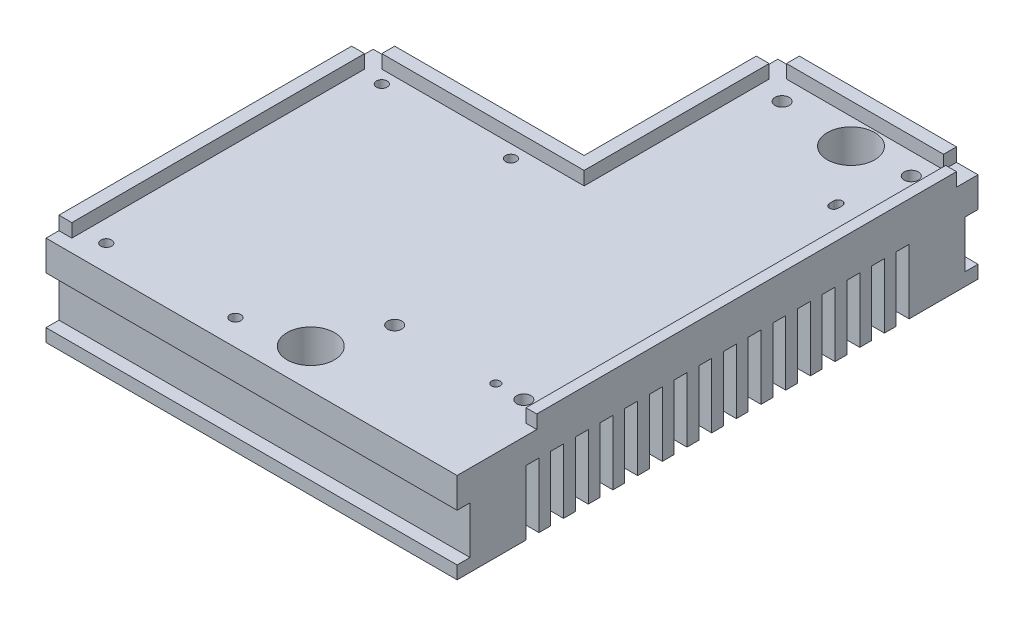
from build123d import *

# Parameters (mm, degrees)
SKETCH_1_W                = 95.5
SKETCH_1_H                = 121
EXTRUDE_1_DEPTH           = 24.125
CUT_EXTRUDE_START         = -3.125
SKETCH_2_W                = 40
SKETCH_2_H                = 70
SKETCH_2_H_2              = 99.5
CUT_EXTRUDE_1_DEPTH       = 3.125
CUT_EXTRUDE_2_DEPTH       = 3.125
HOLE_WIZARD_M3_1_D        = 2.5
HOLE_WIZARD_M3_1_DEPTH    = 5
HOLE_WIZARD_M3_1_TIP      = 0.751075774
HOLE_WIZARD_M4_1_D        = 3.3
HOLE_WIZARD_M4_1_DEPTH    = 5
HOLE_WIZARD_M4_1_TIP      = 0.991420021
MM_2_D                    = 2
MM_2_DEPTH                = 5
MM_2_TIP                  = 0.600860619
CUT_EXTRUDE_12_DEPTH      = 5
SKETCH_27_W               = 49
SKETCH_27_H               = 45
CUT_EXTRUDE_15_DEPTH      = 25.125
CUT_EXTRUDE_16_DEPTH      = 16
CUT_EXTRUDE_17_DEPTH      = 16
FILLET_2_R                = 5
SKETCH_42_W               = 5
SKETCH_42_H               = 5
CUT_EXTRUDE_24_DEPTH      = 3.125
HOLE_WIZARD_2_D           = 6.6
HOLE_WIZARD_2_CBORE_D     = 11
HOLE_WIZARD_2_CBORE_DEPTH = 8
SKETCH_49_W               = 3
SKETCH_49_H               = 11
CUT_EXTRUDE_28_DEPTH      = 96.5
SKETCH_50_W               = 3
SKETCH_50_H               = 3
CUT_EXTRUDE_29_DEPTH      = 4
CUT_EXTRUDE_29_DEPTH_BACK = 13
SKETCH_52_W               = 3
SKETCH_52_H               = 15
CUT_EXTRUDE_30_DEPTH      = 96.5
PATTERN_LINEAR_4_COUNT    = 16
PATTERN_LINEAR_4_PITCH    = 5.733333333
MM_3_D                    = 4
MM_3_DEPTH                = 5
MM_3_TIP                  = 1.201721238


with BuildPart() as part:
    # 草图1 → 凸台-拉伸1 (new body)
    with BuildSketch(Plane(origin=(0, 0, 0), x_dir=(1, 0, 0), z_dir=(0, 1, 0))):
        with Locations((-170.498130707, -443.224508868)):
            Rectangle(SKETCH_1_W, SKETCH_1_H)
    extrude(amount=EXTRUDE_1_DEPTH)

    # 草图2 → 切除-拉伸1 (cut)
    with BuildSketch(Plane(origin=(0, 24.125, 0), x_dir=(1, 0, 0), z_dir=(0, 1, 0)).offset(CUT_EXTRUDE_START)):
        with Locations((-195.248130707, -465.724508868)):
            Rectangle(SKETCH_2_W, SKETCH_2_H)
        with Locations((-145.248130707, -435.474508868)):
            Rectangle(SKETCH_2_W, SKETCH_2_H_2)
    extrude(amount=CUT_EXTRUDE_1_DEPTH, mode=Mode.SUBTRACT)

    # 草图4 → 切除-拉伸2 (cut)
    with BuildSketch(Plane(origin=(0, 24.125, 0), x_dir=(1, 0, 0), z_dir=(0, 1, 0))):
        Polygon((-165.248130707, -385.724508868), (-166.248130707, -385.724508868), (-166.248130707, -430.724508868), (-175.248130707, -430.724508868), (-175.248130707, -500.724508868), (-215.248130707, -500.724508868), (-218.248130707, -500.724508868), (-218.248130707, -503.724508868), (-122.748130707, -503.724508868), (-122.748130707, -485.224508868), (-125.248130707, -485.224508868), (-165.248130707, -485.224508868), align=None)
    extrude(amount=-CUT_EXTRUDE_2_DEPTH, mode=Mode.SUBTRACT)

    # M3 螺纹孔1
    with Locations(Plane(origin=(-210.248130707, 21, 433.724508868), x_dir=(0, 0, 1), z_dir=(0, 1, 0))):
        with Locations((0, 0), (0, 30), (64, 30), (64, 0)):
            Hole(HOLE_WIZARD_M3_1_D / 2, depth=HOLE_WIZARD_M3_1_DEPTH)
            with Locations((0, 0, -(HOLE_WIZARD_M3_1_DEPTH + HOLE_WIZARD_M3_1_TIP / 2))):  # 118° drill point
                Cone(0, HOLE_WIZARD_M3_1_D / 2, HOLE_WIZARD_M3_1_TIP, mode=Mode.SUBTRACT)

    # M4 螺纹孔1
    with Locations(Plane(origin=(-160.248130707, 21, 390.724508868), x_dir=(0, 0, 1), z_dir=(0, 1, 0))):
        with Locations((0, 0), (0, 30), (90, 0), (90, 30)):
            Hole(HOLE_WIZARD_M4_1_D / 2, depth=HOLE_WIZARD_M4_1_DEPTH)
            with Locations((0, 0, -(HOLE_WIZARD_M4_1_DEPTH + HOLE_WIZARD_M4_1_TIP / 2))):  # 118° drill point
                Cone(0, HOLE_WIZARD_M4_1_D / 2, HOLE_WIZARD_M4_1_TIP, mode=Mode.SUBTRACT)

    # 大小mm 暗销孔2
    with Locations(Plane(origin=(-136.748130707, 21, 480.724508868), x_dir=(0, 0, 1), z_dir=(0, 1, 0))):
        with Locations((0, 0)):
            Hole(MM_2_D / 2, depth=MM_2_DEPTH)
            with Locations((0, 0, -(MM_2_DEPTH + MM_2_TIP / 2))):  # 118° drill point
                Cone(0, MM_2_D / 2, MM_2_TIP, mode=Mode.SUBTRACT)

    # 草图24 → 切除-拉伸12 (cut)
    with BuildSketch(Plane(origin=(0, 21, 0), x_dir=(1, 0, 0), z_dir=(0, 1, 0))):
        with BuildLine():
            Line((-134.248130707, -405.724508868), (-134.248130707, -404.724508868))
            ThreePointArc((-134.248130707, -404.724508868), (-133.248130707, -403.724508868), (-132.248130707, -404.724508868))
            Line((-132.248130707, -404.724508868), (-132.248130707, -405.724508868))
            ThreePointArc((-132.248130707, -405.724508868), (-133.248130707, -406.724508868), (-134.248130707, -405.724508868))
        make_face()
    extrude(amount=-CUT_EXTRUDE_12_DEPTH, mode=Mode.SUBTRACT)

    # 草图27 → 切除-拉伸15 (cut, through all)
    with BuildSketch(Plane(origin=(0, 24.125, 0), x_dir=(1, 0, 0), z_dir=(0, 1, 0))):
        with Locations((-193.748130707, -405.224508868)):
            Rectangle(SKETCH_27_W, SKETCH_27_H)
    extrude(amount=-CUT_EXTRUDE_15_DEPTH, mode=Mode.SUBTRACT)

    # 草图28 → 切除-拉伸16 (cut)
    with BuildSketch(Plane(origin=(0, 0, 0), x_dir=(1, 0, 0), z_dir=(0, 1, 0))):
        Polygon((-151.605995083, -389.724508869), (-171.714464048, -409.832977834), (-185.669197391, -395.878244492), (-165.560728425, -375.769775526), align=None)
    extrude(amount=CUT_EXTRUDE_16_DEPTH, mode=Mode.SUBTRACT)

    # 草图29 → 切除-拉伸17 (cut)
    with BuildSketch(Plane.XZ):
        Polygon((-151.605995083, 389.724508869), (-158.605995083, 382.724508868), (-155.777567958, 382.724508868), (-148.777567958, 389.724508869), (-167.833917144, 408.780858055), (-169.248130707, 410.195071617), (-169.248130707, 407.366644492), align=None)
    extrude(amount=-CUT_EXTRUDE_17_DEPTH, mode=Mode.SUBTRACT)

    # 圆角2
    fillet_2_edges = [part.edges().sort_by_distance(p)[0] for p in [
        (-148.777567958, 8, 389.724508869),
    ]]
    fillet(fillet_2_edges, radius=FILLET_2_R)

    # 草图42 → 切除-拉伸24 (cut)
    with BuildSketch(Plane(origin=(0, 24.125, 0), x_dir=(1, 0, 0), z_dir=(0, 1, 0))):
        with Locations((-166.748130707, -385.224508868)):
            Rectangle(SKETCH_42_W, SKETCH_42_H)
        with Locations((-125.248130707, -385.224508868)):
            Rectangle(SKETCH_42_W, SKETCH_42_H)
        with Locations((-215.748130707, -430.224508868)):
            Rectangle(SKETCH_42_W, SKETCH_42_H)
    extrude(amount=-CUT_EXTRUDE_24_DEPTH, mode=Mode.SUBTRACT)

    # 打孔尺寸(%根据)内六角圆柱头螺钉的类型2 (through all)
    with Locations(Plane(origin=(-165.748130707, 21, 494.724508868), x_dir=(0, 0, 1), z_dir=(0, 1, 0))):
        with Locations((0, 0), (-103, 22.5)):
            CounterBoreHole(HOLE_WIZARD_2_D / 2, HOLE_WIZARD_2_CBORE_D / 2, HOLE_WIZARD_2_CBORE_DEPTH)

    # 草图49 → 切除-拉伸28 (cut, through all)
    with BuildSketch(Plane(origin=(-122.748130707, 0, 0), x_dir=(0, 0, -1), z_dir=(1, 0, 0))):
        with Locations((-502.224508868, 8.5)):
            Rectangle(SKETCH_49_W, SKETCH_49_H)
        with Locations((-384.224508868, 8.5)):
            Rectangle(SKETCH_49_W, SKETCH_49_H)
    extrude(amount=-CUT_EXTRUDE_28_DEPTH, mode=Mode.SUBTRACT)

    # 草图50 → 切除-拉伸29 (cut, two sides)
    with BuildSketch(Plane.XZ.offset(-3)) as cut_extrude_29_sk:
        with Locations((-154.277567958, 384.224508868)):
            Rectangle(SKETCH_50_W, SKETCH_50_H)
    extrude(amount=CUT_EXTRUDE_29_DEPTH, mode=Mode.SUBTRACT)
    extrude(cut_extrude_29_sk.sketch, amount=-CUT_EXTRUDE_29_DEPTH_BACK, mode=Mode.SUBTRACT)

    # 草图52 → 切除-拉伸30 (cut, through all)
    with BuildSketch(Plane(origin=(-122.748130707, 0, 0), x_dir=(0, 0, -1), z_dir=(1, 0, 0))):
        with Locations((-400.224508868, 7.5)):
            Rectangle(SKETCH_52_W, SKETCH_52_H)
    cut_extrude_30 = extrude(amount=-CUT_EXTRUDE_30_DEPTH, mode=Mode.SUBTRACT)

    # 阵列(线性)4: 切除-拉伸30 ×16
    with Locations(*[(0, 0, i * PATTERN_LINEAR_4_PITCH) for i in range(1, PATTERN_LINEAR_4_COUNT)]):
        add(cut_extrude_30, mode=Mode.SUBTRACT)

    # 大小mm 暗销孔3
    with Locations(Plane(origin=(-155.748130707, 0, 494.724508868), x_dir=(0, 0, -1), z_dir=(0, -1, 0))):
        with Locations((0, 0), (103, 22.5)):
            Hole(MM_3_D / 2, depth=MM_3_DEPTH)
            with Locations((0, 0, -(MM_3_DEPTH + MM_3_TIP / 2))):  # 118° drill point
                Cone(0, MM_3_D / 2, MM_3_TIP, mode=Mode.SUBTRACT)


solid = part.part
